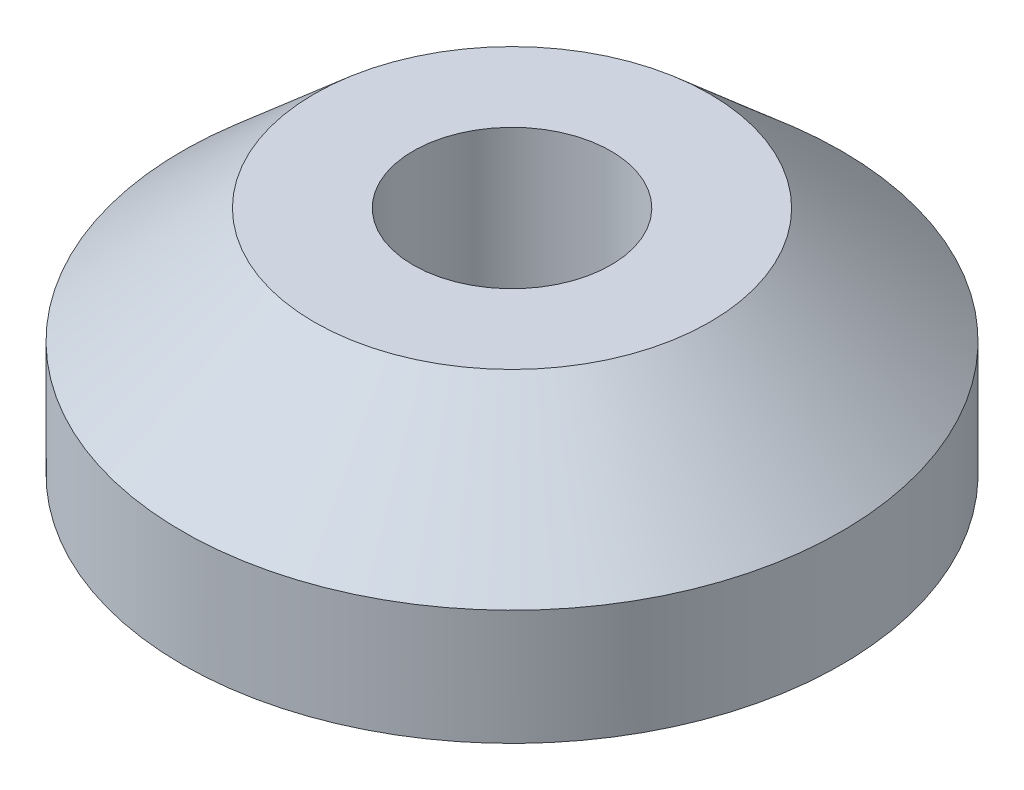
from build123d import *

# Parameters (mm, degrees)
SKETCH2_R           = 10
BOSS_EXTRUDE1_DEPTH = 3.5
SKETCH1_R           = 6
SKETCH3_R           = 3
CUT_EXTRUDE1_DEPTH  = 9.5


with BuildPart() as part:
    # Sketch2 → Boss-Extrude1 (new body)
    with BuildSketch(Plane(origin=(0, -7, 0), x_dir=(1, 0, 0), z_dir=(0, 1, 0))):
        Circle(SKETCH2_R)
    extrude(amount=BOSS_EXTRUDE1_DEPTH)

    # Sketch1 → section 0 of loft1
    with BuildSketch(Plane(origin=(0, 0, 0), x_dir=(1, 0, 0), z_dir=(0, 1, 0)), mode=Mode.PRIVATE) as loft1_s0:
        Circle(SKETCH1_R)
    # loft up to a face of the part (loft1)
    loft([loft1_s0.sketch, part.faces().sort_by_distance((0, -3.5, 0))[0]])

    # Sketch3 → Cut-Extrude1 (cut)
    with BuildSketch(Plane(origin=(0, 0, 0), x_dir=(1, 0, 0), z_dir=(0, 1, 0))):
        Circle(SKETCH3_R)
    extrude(amount=-CUT_EXTRUDE1_DEPTH, mode=Mode.SUBTRACT)


solid = part.part
